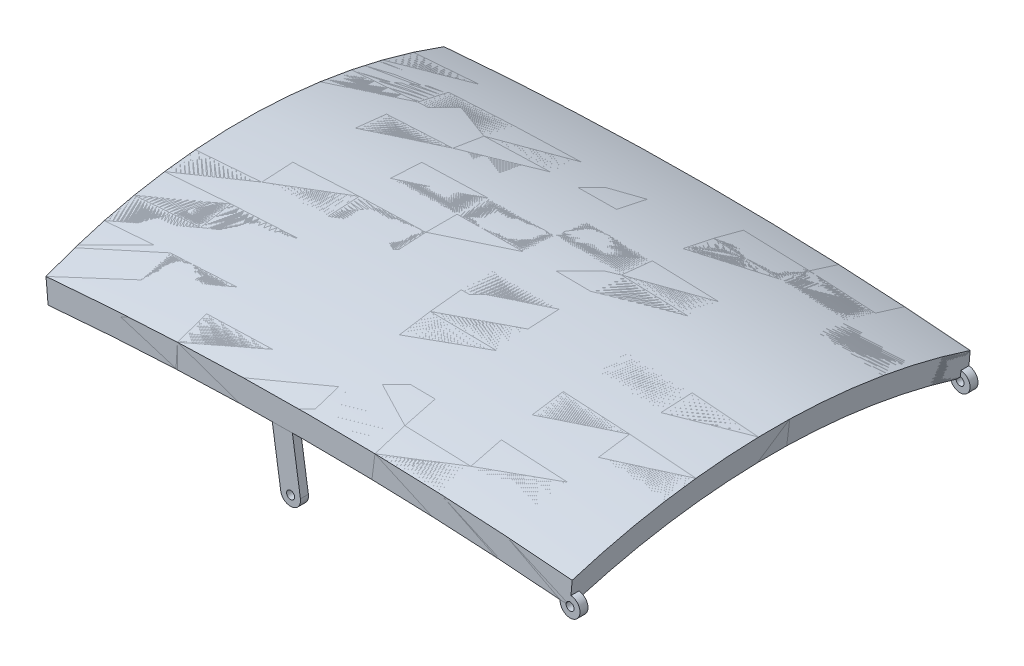
from build123d import *

# Parameters (mm, degrees)
SKETCH3_R               = 10
BOSS_EXTRUDE1_DEPTH     = 20
SKETCH4_R               = 25
BOSS_EXTRUDE2_DEPTH     = 20
SKETCH5_R               = 10
CUT_EXTRUDE1_DEPTH      = 40
SKETCH9_R               = 10
CUT_EXTRUDE2_DEPTH      = 1.0000001
CUT_EXTRUDE2_DEPTH_BACK = 1001.0000001


with BuildPart() as part:
    # Sweep1: sweep along a path in Sketch1
    with BuildLine(Plane.XY) as sweep1_path:
        ThreePointArc((-381.346255507, 0), (274.453744493, 28.976752889), (930.253744493, 0))
    # Sketch2 → Sweep1 (sweep)
    with BuildSketch(Plane(origin=(-381.346255507, 0, 0), x_dir=(0, 0, -1), z_dir=(0.996102918, 0.088198507, 0))):
        with BuildLine():
            Line((1000, 0), (1000, 60))
            ThreePointArc((1000, 60), (500, 145.786437627), (0, 60))
            Line((0, 60), (0, 0))
            ThreePointArc((0, 0), (500, 85.786437627), (1000, 0))
        make_face()
    sweep(path=sweep1_path.line)

    # Sketch4 → Boss-Extrude2 (add)
    with BuildSketch(Plane.XY):
        with Locations((930.253744493, 0)):
            Circle(SKETCH4_R)
    extrude(amount=-BOSS_EXTRUDE2_DEPTH)

    # Sketch5 → Cut-Extrude1 (cut)
    with BuildSketch(Plane.XY):
        with Locations((930.253744493, 0)):
            Circle(SKETCH5_R)
    extrude(amount=-CUT_EXTRUDE1_DEPTH, mode=Mode.SUBTRACT)


with BuildPart() as body_2:
    # Sketch3 → Boss-Extrude1 (new body)
    with BuildSketch(Plane.XY):
        with BuildLine():
            Line((230.462804943, 41.688976459), (179.888879124, 41.688976459))
            Line((179.888879124, 41.688976459), (203.254594848, -112.083465063))
            ThreePointArc((203.254594848, -112.083465063), (231.726528195, -133.044118954), (252.687182085, -104.572185607))
            Line((252.687182085, -104.572185607), (230.462804943, 41.688976459))
        make_face()
        with Locations((227.970888467, -108.327825335)):
            Circle(SKETCH3_R, mode=Mode.SUBTRACT)
    extrude(amount=-BOSS_EXTRUDE1_DEPTH)


with BuildPart() as body_3:
    # Mirror5: mirrored copy
    add(body_2.part.mirror(Plane.XY.offset(-500)))


with BuildPart() as body_4:
    # Mirror5 2: mirrored copy
    add(part.part.mirror(Plane.XY.offset(-500)))


with BuildPart() as cut_extrude2_tool:
    # Sketch9 → Cut-Extrude2 (new body, two sides)
    with BuildSketch(Plane.XY) as cut_extrude2_sk:
        with Locations((930.253744493, 0)):
            Circle(SKETCH9_R)
    extrude(amount=CUT_EXTRUDE2_DEPTH)
    extrude(cut_extrude2_sk.sketch, amount=-CUT_EXTRUDE2_DEPTH_BACK)


with BuildPart() as part_1:
    add(part.part)

    # Cut-Extrude2: cut by cut_extrude2_tool
    add(cut_extrude2_tool.part, mode=Mode.SUBTRACT)


with BuildPart() as body_4_1:
    add(body_4.part)

    # Cut-Extrude2: cut by cut_extrude2_tool
    add(cut_extrude2_tool.part, mode=Mode.SUBTRACT)


solid = Compound([body_2.part, body_3.part, part_1.part, body_4_1.part])
